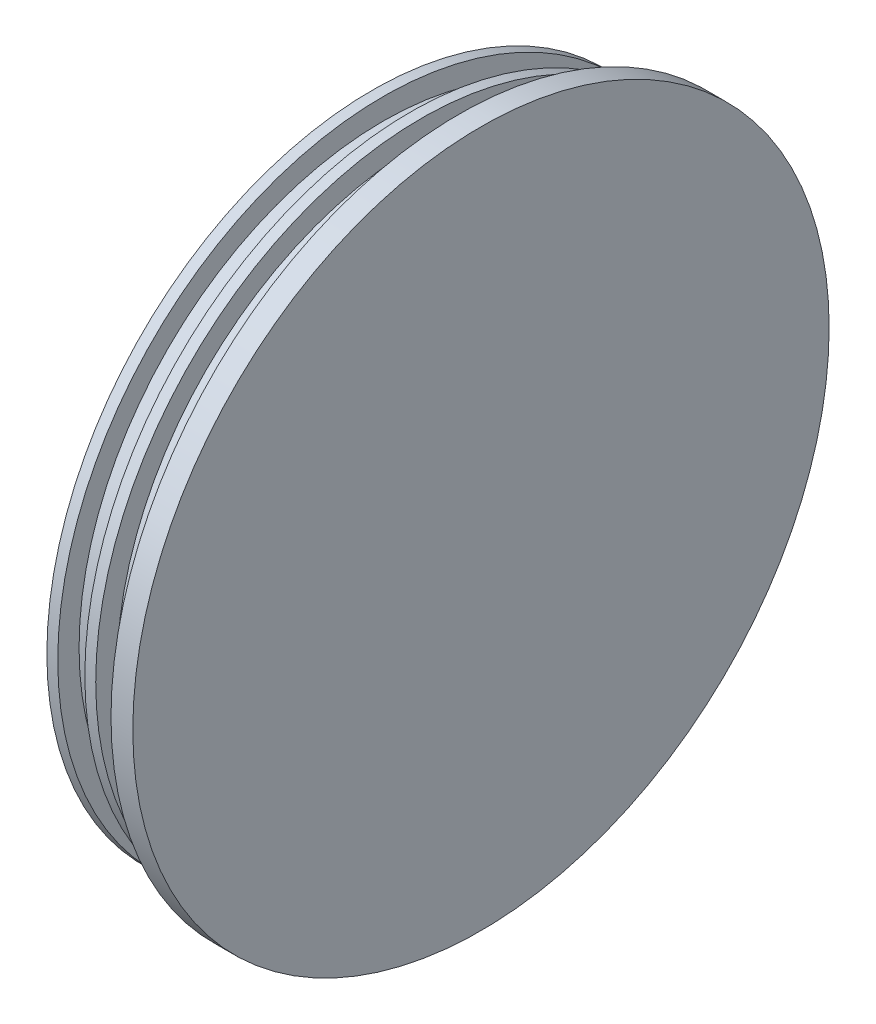
from build123d import *

# Parameters (mm, degrees)
F_6_32_TAPPED_HOLE1_D     = 2.7051
F_6_32_TAPPED_HOLE1_DEPTH = 4.318
F_6_32_TAPPED_HOLE1_TIP   = 0.81269403


with BuildPart() as part:
    # Sketch1 → Revolve1 (revolve)
    with BuildSketch(Plane.XY):
        Polygon((4.318, 50.673), (4.318, 47.371), (2.7305, 47.371), (2.7305, 44.2722), (-1.2065, 44.2722), (-1.2065, 47.371), (-2.794, 47.371), (-2.794, 44.2722), (-6.731, 44.2722), (-6.731, 47.371), (-8.3185, 47.371), (-8.3185, 41.0972), (0, 41.0972), (0, 0), (7.493, 0), (7.493, 50.673), align=None)
    revolve(axis=Axis((0, 0, 0), (1, 0, 0)))

    # #6-32 Tapped Hole1
    with Locations(Plane.ZY):
        with Locations((0, 9.779), (0, -9.779), (-9.779, 0), (9.779, 0)):
            Hole(F_6_32_TAPPED_HOLE1_D / 2, depth=F_6_32_TAPPED_HOLE1_DEPTH)
            with Locations((0, 0, -(F_6_32_TAPPED_HOLE1_DEPTH + F_6_32_TAPPED_HOLE1_TIP / 2))):  # 118° drill point
                Cone(0, F_6_32_TAPPED_HOLE1_D / 2, F_6_32_TAPPED_HOLE1_TIP, mode=Mode.SUBTRACT)


solid = part.part
